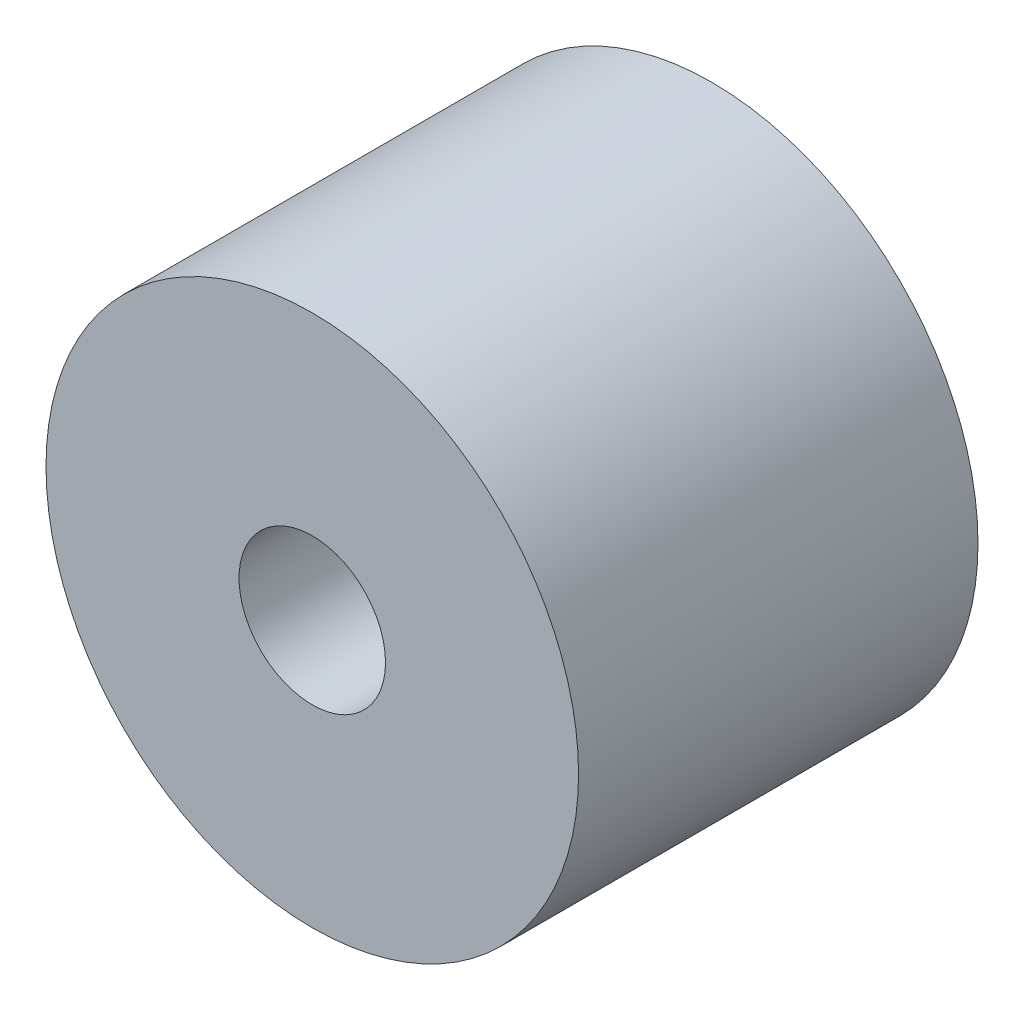
from build123d import *

# Parameters (mm, degrees)
SKETCH1_R           = 10
SKETCH1_R_2         = 2.75
BOSS_EXTRUDE1_DEPTH = 7.5


with BuildPart() as part:
    # Sketch1 → Boss-Extrude1 (new, symmetric)
    with BuildSketch(Plane.XY):
        Circle(SKETCH1_R)
        Circle(SKETCH1_R_2, mode=Mode.SUBTRACT)
    extrude(amount=BOSS_EXTRUDE1_DEPTH, both=True)


solid = part.part
